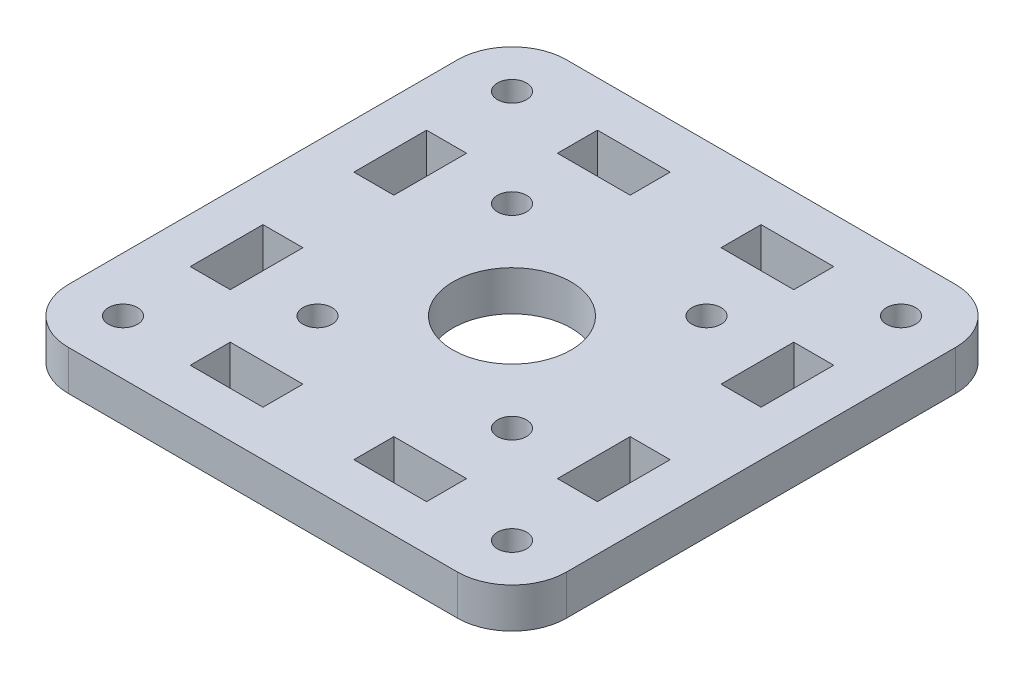
from build123d import *

# Parameters (mm, degrees)
SKETCH_1_W          = 54.8
SKETCH_1_H          = 54.8
SKETCH_1_R          = 6.5
SKETCH_1_R_2        = 1.6
SKETCH_1_W_2        = 4.4
SKETCH_1_H_2        = 8
SKETCH_1_W_3        = 8
SKETCH_1_H_3        = 4.4
EXTRUDE_1_DEPTH     = 4.4
FILLET_1_R          = 6
SKETCH_2_R          = 1.6
CUT_EXTRUDE_1_DEPTH = 10


with BuildPart() as part:
    # 草图1 → 凸台-拉伸1 (new body)
    with BuildSketch(Plane(origin=(0, 0, 0), x_dir=(1, 0, 0), z_dir=(0, 1, 0))):
        Rectangle(SKETCH_1_W, SKETCH_1_H)
        Circle(SKETCH_1_R, mode=Mode.SUBTRACT)
        with Locations((21.4, 21.4)):
            Circle(SKETCH_1_R_2, mode=Mode.SUBTRACT)
        with Locations((21.4, -21.4)):
            Circle(SKETCH_1_R_2, mode=Mode.SUBTRACT)
        with Locations((-21.4, -21.4)):
            Circle(SKETCH_1_R_2, mode=Mode.SUBTRACT)
        with Locations((-21.4, 21.4)):
            Circle(SKETCH_1_R_2, mode=Mode.SUBTRACT)
        with Locations((20.2, 9)):
            Rectangle(SKETCH_1_W_2, SKETCH_1_H_2, mode=Mode.SUBTRACT)
        with Locations((20.2, -9)):
            Rectangle(SKETCH_1_W_2, SKETCH_1_H_2, mode=Mode.SUBTRACT)
        with Locations((-20.2, -9)):
            Rectangle(SKETCH_1_W_2, SKETCH_1_H_2, mode=Mode.SUBTRACT)
        with Locations((-20.2, 9)):
            Rectangle(SKETCH_1_W_2, SKETCH_1_H_2, mode=Mode.SUBTRACT)
        with Locations((9, 20.2)):
            Rectangle(SKETCH_1_W_3, SKETCH_1_H_3, mode=Mode.SUBTRACT)
        with Locations((9, -20.2)):
            Rectangle(SKETCH_1_W_3, SKETCH_1_H_3, mode=Mode.SUBTRACT)
        with Locations((-9, -20.2)):
            Rectangle(SKETCH_1_W_3, SKETCH_1_H_3, mode=Mode.SUBTRACT)
        with Locations((-9, 20.2)):
            Rectangle(SKETCH_1_W_3, SKETCH_1_H_3, mode=Mode.SUBTRACT)
    extrude(amount=EXTRUDE_1_DEPTH)

    # 圆角1
    fillet_1_edges = [part.edges().sort_by_distance(p)[0] for p in [
        (27.4, 2.2, 27.4),
        (-27.4, 2.2, 27.4),
        (-27.4, 2.2, -27.4),
        (27.4, 2.2, -27.4),
    ]]
    fillet(fillet_1_edges, radius=FILLET_1_R)

    # 草图2 → 切除-拉伸1 (cut)
    with BuildSketch(Plane(origin=(0, 4.4, 0), x_dir=(1, 0, 0), z_dir=(0, 1, 0))):
        with Locations((10.7, 10.7)):
            Circle(SKETCH_2_R)
        with Locations((10.7, -10.7)):
            Circle(SKETCH_2_R)
        with Locations((-10.7, -10.7)):
            Circle(SKETCH_2_R)
        with Locations((-10.7, 10.7)):
            Circle(SKETCH_2_R)
    extrude(amount=-CUT_EXTRUDE_1_DEPTH, mode=Mode.SUBTRACT)


solid = part.part
